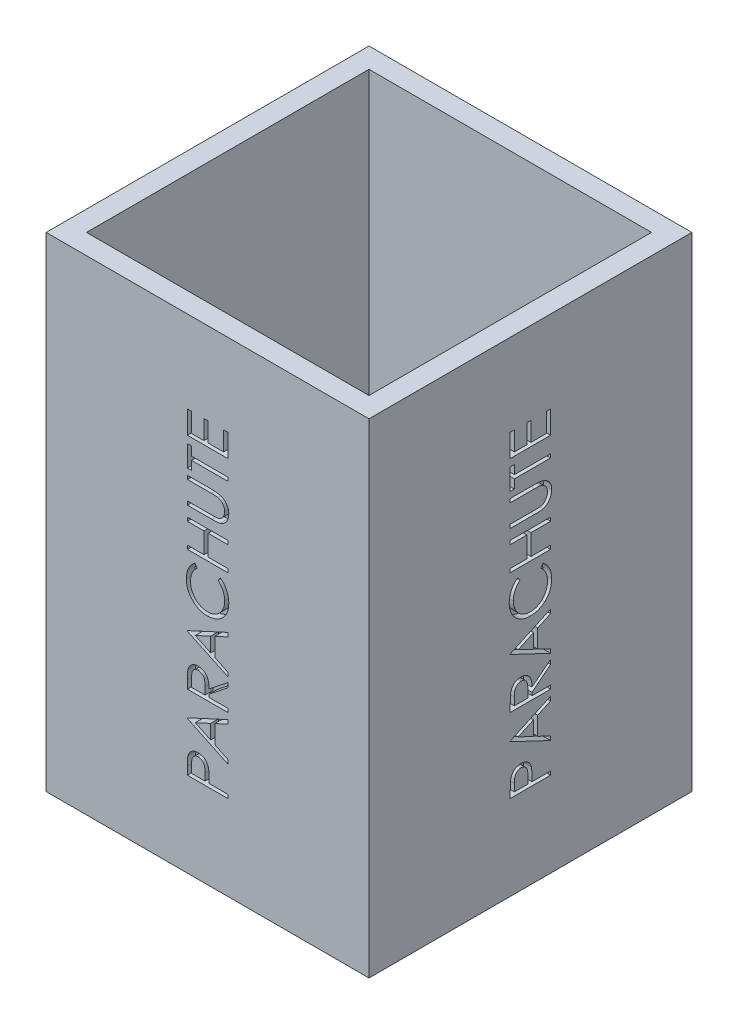
from build123d import *

# Parameters (mm, degrees)
SKETCH1_W           = 101.6
SKETCH1_H           = 101.6
SKETCH1_W_2         = 88.9
SKETCH1_H_2         = 88.9
BOSS_EXTRUDE1_DEPTH = 152.4
CUT_EXTRUDE1_DEPTH  = 2.54
CIRPATTERN1_COUNT   = 4


with BuildPart() as part:
    # Sketch1 → Boss-Extrude1 (new body)
    with BuildSketch(Plane(origin=(0, 0, 0), x_dir=(1, 0, 0), z_dir=(0, 1, 0))):
        Rectangle(SKETCH1_W, SKETCH1_H)
        Rectangle(SKETCH1_W_2, SKETCH1_H_2, mode=Mode.SUBTRACT)
    extrude(amount=BOSS_EXTRUDE1_DEPTH)

    # Sketch6 → Cut-Extrude1 (cut)
    with BuildSketch(Plane.ZY.offset(50.8)):
        with BuildLine():
            Line((-6.35, 26.702564103), (-6.35, 29.193209135))
            add(Edge.make_bspline(
                [(-6.35, 29.193209135), (-6.349811691, 29.36451728), (-6.349450882, 29.692751294), (-6.338511661, 30.163431639), (-6.323900522, 30.590912665), (-6.303646223, 30.974272619), (-6.279710024, 31.314691032), (-6.246138339, 31.610627519), (-6.211085266, 31.864408194), (-6.175447591, 32.01646874), (-6.159194712, 32.085817308)],
                knots=[0, 0, 0, 0, 0.000513909, 0.000984672, 0.001412348, 0.001797041, 0.002136358, 0.002435846, 0.002690583, 0.002904164, 0.002904164, 0.002904164, 0.002904164], degree=3))
            add(Edge.make_bspline(
                [(-6.159194712, 32.085817308), (-6.135165553, 32.173604507), (-6.087673454, 32.347110312), (-5.99256869, 32.597133747), (-5.879734333, 32.83495943), (-5.751382729, 33.061648842), (-5.601195819, 33.273073196), (-5.439164902, 33.476280439), (-5.254818851, 33.664097369), (-5.053971996, 33.839067943), (-4.839171698, 34.000788389), (-4.60651531, 34.136662806), (-4.36294889, 34.255467165), (-4.105162168, 34.352738322), (-3.832904869, 34.425073195), (-3.548111823, 34.478774551), (-3.250462794, 34.513016519), (-3.047042823, 34.516284908), (-2.943489583, 34.517948718)],
                knots=[0, 0, 0, 0, 0.000272928, 0.000539425, 0.000801167, 0.00106213, 0.001319735, 0.001578393, 0.001841062, 0.00210791, 0.002377077, 0.00264628, 0.002914809, 0.003189345, 0.003471382, 0.003758783, 0.004058271, 0.004368814, 0.004368814, 0.004368814, 0.004368814], degree=3))
            add(Edge.make_bspline(
                [(-2.943489583, 34.517948718), (-2.839067365, 34.516419548), (-2.634758241, 34.513427624), (-2.335862696, 34.477518246), (-2.050227394, 34.429148694), (-1.778485674, 34.354773675), (-1.522251307, 34.257362233), (-1.277608551, 34.14309107), (-1.048719455, 34.005265117), (-0.834753057, 33.846896735), (-0.635508519, 33.670723806), (-0.452429693, 33.477491716), (-0.286588236, 33.267980569), (-0.137612361, 33.042856204), (-0.008956718, 32.799923895), (0.106276931, 32.542868081), (0.20305478, 32.269454438), (0.25396386, 32.080251602), (0.279847756, 31.984054487)],
                knots=[0, 0, 0, 0, 0.000313086, 0.000612574, 0.000902017, 0.001181599, 0.001456135, 0.001723565, 0.001990583, 0.002256192, 0.00252113, 0.002787469, 0.003053674, 0.003321805, 0.003596116, 0.003877417, 0.00416629, 0.004465075, 0.004465075, 0.004465075, 0.004465075], degree=3))
            add(Edge.make_bspline(
                [(0.279847756, 31.984054487), (0.296755106, 31.904488684), (0.333808547, 31.730115599), (0.375455577, 31.442958585), (0.409610691, 31.108452841), (0.441484518, 30.727736504), (0.458373661, 30.299921753), (0.47820427, 29.825989789), (0.487561251, 29.304336667), (0.488152728, 28.940499878), (0.488461538, 28.750540865)],
                knots=[0, 0, 0, 0, 0.000243979, 0.000534694, 0.000869865, 0.001252695, 0.001680583, 0.002154115, 0.002675749, 0.003245626, 0.003245626, 0.003245626, 0.003245626], degree=3))
            Line((0.488461538, 28.750540865), (0.488461538, 27.842307692))
            Line((0.488461538, 27.842307692), (6.35, 27.842307692))
            Line((6.35, 27.842307692), (6.35, 26.702564103))
            Line((6.35, 26.702564103), (-6.35, 26.702564103))
        make_face()
        with BuildLine():
            Line((-5.047435897, 27.842307692), (-0.814102564, 27.842307692))
            Line((-0.814102564, 27.842307692), (-0.786117788, 30.065825321))
            add(Edge.make_bspline(
                [(-0.786117788, 30.065825321), (-0.786058006, 30.174392668), (-0.785942597, 30.383979693), (-0.800452377, 30.686723835), (-0.816979073, 30.967643421), (-0.841974741, 31.225682077), (-0.874740105, 31.46174521), (-0.915487111, 31.673793811), (-0.959785588, 31.864999411), (-1.033797354, 32.084944414), (-1.147598039, 32.332169843), (-1.313260324, 32.602244754), (-1.527867901, 32.829357668), (-1.768488369, 33.02552971), (-2.035447832, 33.184268992), (-2.322580965, 33.296253222), (-2.62563392, 33.365208488), (-2.832880378, 33.37382034), (-2.938401442, 33.378205128)],
                knots=[0, 0, 0, 0, 0.000325651, 0.000628662, 0.000909076, 0.001169816, 0.001406195, 0.001623739, 0.00181749, 0.001994481, 0.002318937, 0.002632302, 0.002940177, 0.003251283, 0.003561503, 0.003867638, 0.004172555, 0.00448885, 0.00448885, 0.00448885, 0.00448885], degree=3))
            add(Edge.make_bspline(
                [(-2.938401442, 33.378205128), (-3.040503948, 33.37362348), (-3.243471094, 33.36451573), (-3.540938354, 33.296822267), (-3.824816581, 33.183066489), (-4.089626181, 33.025390932), (-4.329717186, 32.833979681), (-4.538638533, 32.61168204), (-4.705467251, 32.357929303), (-4.81729303, 32.123848407), (-4.882763075, 31.914231844), (-4.930049703, 31.733057963), (-4.962657093, 31.527446796), (-4.993858298, 31.299351961), (-5.019043897, 31.049063059), (-5.036533738, 30.774989312), (-5.046662216, 30.478043413), (-5.04717176, 30.271903167), (-5.047435897, 30.165044071)],
                knots=[0, 0, 0, 0, 0.000306146, 0.00060858, 0.000909985, 0.001220206, 0.001529716, 0.001828533, 0.002131234, 0.002437391, 0.002603127, 0.00278947, 0.002998595, 0.003227067, 0.003480211, 0.003753009, 0.004050839, 0.004371402, 0.004371402, 0.004371402, 0.004371402], degree=3))
            Line((-5.047435897, 30.165044071), (-5.047435897, 27.842307692))
        make_face(mode=Mode.SUBTRACT)
        Polygon((-6.35, 42.333333333), (6.35, 48.194871795), (6.35, 46.955909455), (2.279487179, 45.078385417), (2.279487179, 39.321153846), (6.35, 37.390204327), (6.35, 36.146153846), (-6.35, 42.170512821), align=None)
        Polygon((-3.874619391, 42.239202724), (0.976923077, 39.939362981), (0.976923077, 44.477984776), align=None, mode=Mode.SUBTRACT)
        with BuildLine():
            Line((-6.35, 50.148717949), (-6.35, 52.690244391))
            add(Edge.make_bspline(
                [(-6.35, 52.690244391), (-6.349435445, 52.859847914), (-6.348351437, 53.185505467), (-6.342307098, 53.652042762), (-6.324983007, 54.075958229), (-6.310074718, 54.457030217), (-6.282889674, 54.795251736), (-6.256906754, 55.091659906), (-6.222893757, 55.344889551), (-6.191305508, 55.49818164), (-6.177003205, 55.567588141)],
                knots=[0, 0, 0, 0, 0.00050882, 0.000976992, 0.001399583, 0.001781609, 0.002120925, 0.002417362, 0.00267425, 0.002886798, 0.002886798, 0.002886798, 0.002886798], degree=3))
            add(Edge.make_bspline(
                [(-6.177003205, 55.567588141), (-6.154046023, 55.660503534), (-6.108621399, 55.844352181), (-6.012611744, 56.109057754), (-5.90150294, 56.361291577), (-5.771018077, 56.600028753), (-5.620116216, 56.823989125), (-5.451671078, 57.035797324), (-5.266022884, 57.234765808), (-5.061498078, 57.418297883), (-4.842454358, 57.585009447), (-4.609492898, 57.731241166), (-4.363576943, 57.854804281), (-4.104323463, 57.95176961), (-3.834596302, 58.033134175), (-3.551642489, 58.08780114), (-3.256406611, 58.121853318), (-3.055524074, 58.125217338), (-2.953665865, 58.126923077)],
                knots=[0, 0, 0, 0, 0.00028695, 0.000567779, 0.000843397, 0.001113237, 0.001382776, 0.001652556, 0.001924343, 0.002198159, 0.002475975, 0.002749152, 0.003022211, 0.003300027, 0.003578554, 0.003866439, 0.004163398, 0.004468856, 0.004468856, 0.004468856, 0.004468856], degree=3))
            add(Edge.make_bspline(
                [(-2.953665865, 58.126923077), (-2.784447057, 58.121592712), (-2.454257334, 58.11119179), (-1.975064993, 58.014217843), (-1.528063765, 57.855371614), (-1.113816479, 57.636484251), (-0.740397852, 57.357739296), (-0.412409628, 57.022732197), (-0.137944802, 56.631276064), (0.052383946, 56.266861118), (0.174278215, 55.944955307), (0.260044431, 55.679948715), (0.326309276, 55.390871397), (0.385673183, 55.080493069), (0.430492189, 54.74752209), (0.463318403, 54.392756519), (0.483834522, 54.01594334), (0.486889797, 53.757084431), (0.488461538, 53.623918269)],
                knots=[0, 0, 0, 0, 0.00050719, 0.000989658, 0.001459589, 0.001926202, 0.002389733, 0.002852089, 0.003326461, 0.003819151, 0.004080894, 0.004358478, 0.00465405, 0.004969894, 0.005306299, 0.005661468, 0.00603854, 0.006438032, 0.006438032, 0.006438032, 0.006438032], degree=3))
            Line((0.488461538, 53.623918269), (6.35, 58.28974359))
            Line((6.35, 58.28974359), (6.35, 56.880328526))
            Line((6.35, 56.880328526), (0.488461538, 52.214503205))
            Line((0.488461538, 52.214503205), (0.488461538, 51.288461538))
            Line((0.488461538, 51.288461538), (6.35, 51.288461538))
            Line((6.35, 51.288461538), (6.35, 50.148717949))
            Line((6.35, 50.148717949), (-6.35, 50.148717949))
        make_face()
        with BuildLine():
            Line((-5.047435897, 51.288461538), (-0.814102564, 51.288461538))
            Line((-0.814102564, 51.288461538), (-0.796294071, 53.613741987))
            add(Edge.make_bspline(
                [(-0.796294071, 53.613741987), (-0.796246012, 53.722309), (-0.796152862, 53.932742792), (-0.810644942, 54.237182155), (-0.827129411, 54.520647212), (-0.8523499, 54.782050053), (-0.884833542, 55.021519598), (-0.92553037, 55.2388964), (-0.972740819, 55.434664989), (-1.046568732, 55.662248342), (-1.158427533, 55.919384806), (-1.332164348, 56.192726377), (-1.540921912, 56.432561675), (-1.786526872, 56.627889712), (-2.052278924, 56.791542785), (-2.340899864, 56.901674794), (-2.643027109, 56.975073102), (-2.850612056, 56.983097499), (-2.956209936, 56.987179487)],
                knots=[0, 0, 0, 0, 0.000325651, 0.000631204, 0.000914157, 0.001177428, 0.001418847, 0.001638891, 0.00184066, 0.002022485, 0.002356224, 0.00267876, 0.002990603, 0.003305287, 0.003616809, 0.003922944, 0.004228423, 0.004544718, 0.004544718, 0.004544718, 0.004544718], degree=3))
            add(Edge.make_bspline(
                [(-2.956209936, 56.987179487), (-3.058333461, 56.982804915), (-3.260705025, 56.97413611), (-3.557121418, 56.903749436), (-3.836966004, 56.783416378), (-4.100600104, 56.625117706), (-4.336171695, 56.426452197), (-4.539918699, 56.197980897), (-4.706713674, 55.939747774), (-4.817571655, 55.700519642), (-4.882673658, 55.484979882), (-4.929991835, 55.298728811), (-4.962832413, 55.087248131), (-4.993938428, 54.85149959), (-5.019119587, 54.591033275), (-5.036489208, 54.305085784), (-5.046661639, 53.995428469), (-5.047171805, 53.780810574), (-5.047435897, 53.669711538)],
                knots=[0, 0, 0, 0, 0.000306146, 0.000606669, 0.000907656, 0.001216998, 0.001525796, 0.001828552, 0.002131979, 0.002445065, 0.002615651, 0.002806931, 0.003021071, 0.003257108, 0.00352038, 0.003805872, 0.004116415, 0.004449698, 0.004449698, 0.004449698, 0.004449698], degree=3))
            Line((-5.047435897, 53.669711538), (-5.047435897, 51.288461538))
        make_face(mode=Mode.SUBTRACT)
        Polygon((-6.35, 66.105128205), (6.35, 71.966666667), (6.35, 70.727704327), (2.279487179, 68.850180288), (2.279487179, 63.092948718), (6.35, 61.161999199), (6.35, 59.917948718), (-6.35, 65.942307692), align=None)
        Polygon((-3.874619391, 66.010997596), (0.976923077, 63.711157853), (0.976923077, 68.249779647), align=None, mode=Mode.SUBTRACT)
        with BuildLine():
            Line((-4.01963141, 85.643589744), (-3.256410256, 84.646314103))
            add(Edge.make_bspline(
                [(-3.256410256, 84.646314103), (-3.341194225, 84.575172007), (-3.509619091, 84.433846965), (-3.746144204, 84.206494291), (-3.96766222, 83.969502521), (-4.175596423, 83.723201398), (-4.361589506, 83.461890944), (-4.540126766, 83.195527823), (-4.696442281, 82.914433884), (-4.887401238, 82.527708494), (-5.082322078, 82.019833108), (-5.249970827, 81.382710967), (-5.355686274, 80.716701853), (-5.36721364, 80.262430786), (-5.373076923, 80.031370192)],
                knots=[0, 0, 0, 0, 0.00033196, 0.000659444, 0.000983431, 0.001304932, 0.001625525, 0.001945168, 0.002266407, 0.002589534, 0.003238685, 0.003894034, 0.004563275, 0.005256052, 0.005256052, 0.005256052, 0.005256052], degree=3))
            add(Edge.make_bspline(
                [(-5.373076923, 80.031370192), (-5.371611116, 79.904067935), (-5.368693107, 79.650644904), (-5.330197138, 79.274549015), (-5.276090748, 78.905475943), (-5.195807431, 78.543665767), (-5.094306788, 78.189579028), (-4.973020274, 77.840900899), (-4.822961328, 77.50267952), (-4.657105476, 77.170236421), (-4.469772216, 76.851722462), (-4.265432984, 76.550354267), (-4.046387468, 76.267213356), (-3.811766703, 76.002140319), (-3.562803693, 75.754626421), (-3.296709232, 75.527786263), (-3.01632795, 75.318589086), (-2.721427006, 75.128227146), (-2.414752947, 74.956857194), (-2.09455485, 74.812761711), (-1.766315152, 74.686909691), (-1.427706865, 74.585757323), (-1.080980558, 74.506315432), (-0.72469984, 74.451392965), (-0.359540199, 74.413343137), (-0.112038264, 74.410438502), (0.012720353, 74.408974359)],
                knots=[0, 0, 0, 0, 0.000381746, 0.00075995, 0.001133062, 0.001500343, 0.001870765, 0.002237676, 0.002606812, 0.002979993, 0.003351741, 0.00371443, 0.004071661, 0.004424911, 0.004775707, 0.005123948, 0.005472996, 0.005824418, 0.006176292, 0.006525803, 0.006876866, 0.007230199, 0.007585067, 0.007943095, 0.008311168, 0.008685285, 0.008685285, 0.008685285, 0.008685285], degree=3))
            add(Edge.make_bspline(
                [(0.012720353, 74.408974359), (0.200426958, 74.413563695), (0.568963978, 74.422574249), (1.108848166, 74.5024258), (1.62655408, 74.624742731), (2.118576381, 74.805061109), (2.58901667, 75.031840079), (3.032169897, 75.314797703), (3.454528385, 75.643752538), (3.845862858, 76.022079241), (4.203321893, 76.437219895), (4.518103914, 76.88261655), (4.780503276, 77.357177449), (4.998856092, 77.855658158), (5.166701906, 78.381895828), (5.284863161, 78.934943809), (5.361941929, 79.513599339), (5.369321311, 79.90900259), (5.373076923, 80.110236378)],
                knots=[0, 0, 0, 0, 0.000562815, 0.001105012, 0.001633818, 0.002156121, 0.002673826, 0.003197534, 0.003730369, 0.00427735, 0.004827582, 0.005371763, 0.005910445, 0.006451621, 0.007001941, 0.007564319, 0.008146516, 0.008749895, 0.008749895, 0.008749895, 0.008749895], degree=3))
            add(Edge.make_bspline(
                [(5.373076923, 80.110236378), (5.366949065, 80.33195185), (5.354887975, 80.768340936), (5.252710128, 81.408304918), (5.087037112, 82.020937553), (4.855178937, 82.606271796), (4.553770606, 83.162657512), (4.188381165, 83.690965393), (3.755534929, 84.191641378), (3.425033292, 84.492708602), (3.256410256, 84.646314103)],
                knots=[0, 0, 0, 0, 0.000664826, 0.001308536, 0.001938654, 0.00256556, 0.003192755, 0.00383282, 0.004489298, 0.005173128, 0.005173128, 0.005173128, 0.005173128], degree=3))
            Line((3.256410256, 84.646314103), (4.011999199, 85.643589744))
            add(Edge.make_bspline(
                [(4.011999199, 85.643589744), (4.115549426, 85.563329788), (4.322153882, 85.403194317), (4.613478666, 85.143945536), (4.887251894, 84.870640569), (5.142106353, 84.58257691), (5.379096924, 84.279246831), (5.598352345, 83.960678166), (5.798709025, 83.627142843), (5.982746472, 83.281290095), (6.144785206, 82.922322973), (6.288375195, 82.553401622), (6.407251844, 82.172264027), (6.507808151, 81.782118528), (6.579509323, 81.379441554), (6.636606518, 80.968913926), (6.670480805, 80.54669325), (6.673905521, 80.262092454), (6.675641026, 80.11786859)],
                knots=[0, 0, 0, 0, 0.00039295, 0.000784017, 0.001168988, 0.001552873, 0.001937104, 0.002323107, 0.002712292, 0.003103781, 0.003497718, 0.003893163, 0.004290641, 0.004694796, 0.005100972, 0.005516895, 0.005937967, 0.006370579, 0.006370579, 0.006370579, 0.006370579], degree=3))
            add(Edge.make_bspline(
                [(6.675641026, 80.11786859), (6.674690367, 79.981275855), (6.672810557, 79.711180637), (6.642358978, 79.312405167), (6.60081279, 78.92418583), (6.538255743, 78.547632188), (6.464434852, 78.180689364), (6.365479149, 77.826683815), (6.254629316, 77.482132052), (6.124345507, 77.148418358), (5.977329645, 76.825258876), (5.811171703, 76.513695903), (5.627268936, 76.213872734), (5.429675042, 75.922841636), (5.212043118, 75.644901832), (4.977395615, 75.377644755), (4.726523405, 75.119571769), (4.545621508, 74.959904884), (4.454667468, 74.879627404)],
                knots=[0, 0, 0, 0, 0.000409666, 0.000810065, 0.001199174, 0.001580615, 0.001954827, 0.00232143, 0.002682661, 0.003040299, 0.003395496, 0.003747176, 0.004098847, 0.004450261, 0.004801913, 0.005157073, 0.005516877, 0.005880706, 0.005880706, 0.005880706, 0.005880706], degree=3))
            add(Edge.make_bspline(
                [(4.454667468, 74.879627404), (4.296671895, 74.751055027), (3.982588209, 74.495462512), (3.473598494, 74.168311551), (2.942643322, 73.889205781), (2.386647308, 73.661019374), (1.80539431, 73.485745594), (1.199819394, 73.362516732), (0.571133136, 73.282997336), (0.143559958, 73.273870165), (-0.073778045, 73.269230769)],
                knots=[0, 0, 0, 0, 0.000610709, 0.001214046, 0.001811469, 0.002408161, 0.003014189, 0.003629886, 0.004260364, 0.004912143, 0.004912143, 0.004912143, 0.004912143], degree=3))
            add(Edge.make_bspline(
                [(-0.073778045, 73.269230769), (-0.302216405, 73.2748739), (-0.751654617, 73.285976408), (-1.41123439, 73.380304009), (-2.04315518, 73.532046498), (-2.646237339, 73.747572351), (-3.223652928, 74.020823197), (-3.770991014, 74.35837691), (-4.291751972, 74.756311969), (-4.77803407, 75.211507429), (-5.222676864, 75.710680331), (-5.613859375, 76.24523717), (-5.93940579, 76.814131663), (-6.211534722, 77.411096439), (-6.420701774, 78.040601627), (-6.567126194, 78.701304138), (-6.658265445, 79.391962485), (-6.669786913, 79.863177573), (-6.675641026, 80.102604167)],
                knots=[0, 0, 0, 0, 0.000685036, 0.001347765, 0.001994424, 0.002631723, 0.003265569, 0.003907406, 0.004557186, 0.005228594, 0.005902557, 0.006560016, 0.007211953, 0.007865497, 0.008525192, 0.009197944, 0.009893113, 0.01061119, 0.01061119, 0.01061119, 0.01061119], degree=3))
            add(Edge.make_bspline(
                [(-6.675641026, 80.102604167), (-6.673890031, 80.248524772), (-6.670424115, 80.537359915), (-6.636678167, 80.964640763), (-6.580304858, 81.380603128), (-6.5039791, 81.78568448), (-6.407862207, 82.181055936), (-6.288069769, 82.565977821), (-6.145448455, 82.939507559), (-5.982581524, 83.301523802), (-5.799438593, 83.64958274), (-5.598179886, 83.983465869), (-5.379822309, 84.301842086), (-5.142130377, 84.603056607), (-4.887075716, 84.887477964), (-4.617645938, 85.159325284), (-4.326927265, 85.410685353), (-4.12225087, 85.565812832), (-4.01963141, 85.643589744)],
                knots=[0, 0, 0, 0, 0.000437698, 0.00086638, 0.001284824, 0.001696468, 0.002102476, 0.00250481, 0.002905006, 0.003301261, 0.003695, 0.004084185, 0.004470188, 0.004852417, 0.005234401, 0.005615774, 0.005999895, 0.006386133, 0.006386133, 0.006386133, 0.006386133], degree=3))
        make_face()
        Polygon((-6.35, 88.248717949), (-6.35, 89.388461538), (-1.13974359, 89.388461538), (-1.13974359, 95.901282051), (-6.35, 95.901282051), (-6.35, 97.041025641), (6.35, 97.041025641), (6.35, 95.901282051), (0.162820513, 95.901282051), (0.162820513, 89.388461538), (6.35, 89.388461538), (6.35, 88.248717949), align=None)
        with BuildLine():
            Line((-6.35, 100.297435897), (-6.35, 101.437179487))
            Line((-6.35, 101.437179487), (1.259314904, 101.437179487))
            add(Edge.make_bspline(
                [(1.259314904, 101.437179487), (1.367013574, 101.437009873), (1.571390359, 101.436688002), (1.862286764, 101.438837981), (2.120903972, 101.444859118), (2.348238862, 101.448655182), (2.54324826, 101.457100078), (2.706988673, 101.463987277), (2.838684779, 101.472843011), (2.915541282, 101.483486038), (2.948577724, 101.488060897)],
                knots=[0, 0, 0, 0, 0.000323097, 0.000613132, 0.000872677, 0.001099157, 0.001295199, 0.001458198, 0.00159088, 0.001690911, 0.001690911, 0.001690911, 0.001690911], degree=3))
            add(Edge.make_bspline(
                [(2.948577724, 101.488060897), (3.068678382, 101.506633679), (3.300527304, 101.5424876), (3.630446706, 101.637744774), (3.928333977, 101.764737933), (4.200908402, 101.922280542), (4.446437741, 102.121336309), (4.666806461, 102.368470192), (4.867065616, 102.659251411), (5.041662807, 102.989513926), (5.186680487, 103.341409214), (5.295190931, 103.702321833), (5.361599253, 104.065286178), (5.369268516, 104.308320366), (5.373076923, 104.42900641)],
                knots=[0, 0, 0, 0, 0.000364309, 0.000703282, 0.001026979, 0.001333716, 0.001644822, 0.00197083, 0.002323687, 0.002701556, 0.003089433, 0.003463723, 0.003830537, 0.004192368, 0.004192368, 0.004192368, 0.004192368], degree=3))
            add(Edge.make_bspline(
                [(5.373076923, 104.42900641), (5.36920198, 104.532624806), (5.361474476, 104.739263125), (5.313032734, 105.046127938), (5.227450106, 105.345941144), (5.110870945, 105.636347448), (4.967509828, 105.912627255), (4.795765541, 106.167697101), (4.595716709, 106.396281099), (4.374007387, 106.604876736), (4.124166619, 106.785453234), (3.852221844, 106.945111094), (3.550921773, 107.071908788), (3.339302839, 107.136106076), (3.230969551, 107.168970353)],
                knots=[0, 0, 0, 0, 0.000310887, 0.000619979, 0.000929248, 0.001244353, 0.001557284, 0.001861405, 0.002164395, 0.002466808, 0.002772626, 0.003087238, 0.003410935, 0.003750452, 0.003750452, 0.003750452, 0.003750452], degree=3))
            add(Edge.make_bspline(
                [(3.230969551, 107.168970353), (3.186161867, 107.179856521), (3.08631229, 107.204115293), (2.917506464, 107.226783142), (2.718336486, 107.250392534), (2.487371337, 107.266773974), (2.225384951, 107.282744117), (1.931012531, 107.292298409), (1.605322987, 107.2967145), (1.378039571, 107.298030512), (1.259314904, 107.298717949)],
                knots=[0, 0, 0, 0, 0.000138249, 0.000308074, 0.000510355, 0.000740013, 0.001002497, 0.001297784, 0.001623465, 0.001979644, 0.001979644, 0.001979644, 0.001979644], degree=3))
            Line((1.259314904, 107.298717949), (-6.35, 107.298717949))
            Line((-6.35, 107.298717949), (-6.35, 108.438461538))
            Line((-6.35, 108.438461538), (1.320372596, 108.438461538))
            add(Edge.make_bspline(
                [(1.320372596, 108.438461538), (1.458615258, 108.437539313), (1.728404218, 108.435739535), (2.123742387, 108.420136409), (2.498764718, 108.395248853), (2.853529306, 108.360117056), (3.186740279, 108.313461173), (3.500592422, 108.262057029), (3.793355353, 108.195449948), (4.068406804, 108.118226251), (4.331553134, 108.031205693), (4.580802879, 107.916518127), (4.823476525, 107.78786459), (5.056856775, 107.636510483), (5.279460865, 107.46238417), (5.49705116, 107.272156633), (5.703142885, 107.059122901), (5.900277849, 106.829575323), (6.083613417, 106.585057266), (6.243156923, 106.323989883), (6.373068597, 106.047814499), (6.488367768, 105.763070746), (6.570319481, 105.462931725), (6.632631113, 105.151136095), (6.667739227, 104.825834439), (6.672984763, 104.604625253), (6.675641026, 104.492608173)],
                knots=[0, 0, 0, 0, 0.000414715, 0.000809341, 0.001186722, 0.001542137, 0.001878541, 0.00219599, 0.002495942, 0.002778655, 0.003053002, 0.003326297, 0.003600609, 0.00387652, 0.00415945, 0.004447841, 0.004742887, 0.005047804, 0.005355132, 0.005658805, 0.005963754, 0.006269889, 0.006579158, 0.006895484, 0.007223067, 0.007559125, 0.007559125, 0.007559125, 0.007559125], degree=3))
            add(Edge.make_bspline(
                [(6.675641026, 104.492608173), (6.672795422, 104.370436537), (6.667212359, 104.130736224), (6.63517043, 103.777550733), (6.57497125, 103.43890745), (6.497823064, 103.111501306), (6.393158723, 102.798495409), (6.264554163, 102.499982001), (6.117732517, 102.212533523), (5.944239595, 101.942626122), (5.755057241, 101.688045663), (5.547261169, 101.456690234), (5.328765317, 101.242686858), (5.091342218, 101.055468326), (4.839852139, 100.887953412), (4.573112207, 100.74383339), (4.291479998, 100.62003933), (4.095705409, 100.556154235), (3.996734776, 100.523858173)],
                knots=[0, 0, 0, 0, 0.000366567, 0.000719203, 0.001062587, 0.001397642, 0.001727489, 0.002051186, 0.002372062, 0.002694598, 0.003012607, 0.003322545, 0.003626612, 0.003928971, 0.004228146, 0.004532096, 0.004837426, 0.005149591, 0.005149591, 0.005149591, 0.005149591], degree=3))
            add(Edge.make_bspline(
                [(3.996734776, 100.523858173), (3.929125148, 100.505072485), (3.782478361, 100.464325909), (3.53977596, 100.420691257), (3.26032183, 100.384009732), (2.944096843, 100.349518135), (2.590855899, 100.329165631), (2.200752118, 100.311322353), (1.7733138, 100.297310194), (1.475573129, 100.297392825), (1.320372596, 100.297435897)],
                knots=[0, 0, 0, 0, 0.000210421, 0.000456408, 0.000738845, 0.001056039, 0.001410405, 0.001800055, 0.002227648, 0.00269322, 0.00269322, 0.00269322, 0.00269322], degree=3))
            Line((1.320372596, 100.297435897), (-6.35, 100.297435897))
        make_face()
        Polygon((-5.047435897, 110.392307692), (-6.35, 110.392307692), (-6.35, 117.067948718), (-5.047435897, 117.067948718), (-5.047435897, 114.3), (6.35, 114.3), (6.35, 113.16025641), (-5.047435897, 113.16025641), align=None)
        Polygon((-6.35, 119.347435897), (-6.35, 126.511538462), (-5.047435897, 126.511538462), (-5.047435897, 120.487179487), (-1.13974359, 120.487179487), (-1.13974359, 126.511538462), (0.162820513, 126.511538462), (0.162820513, 120.487179487), (5.047435897, 120.487179487), (5.047435897, 126.511538462), (6.35, 126.511538462), (6.35, 119.347435897), align=None)
    cut_extrude1 = extrude(amount=-CUT_EXTRUDE1_DEPTH, mode=Mode.SUBTRACT)

    # CirPattern1: Cut-Extrude1 ×4 about axis
    cirpattern1_axis = Axis((0, 0, 0), (0, 1, 0))
    for i in range(1, CIRPATTERN1_COUNT):
        add(cut_extrude1.rotate(cirpattern1_axis, i * 360 / CIRPATTERN1_COUNT), mode=Mode.SUBTRACT)


solid = part.part
